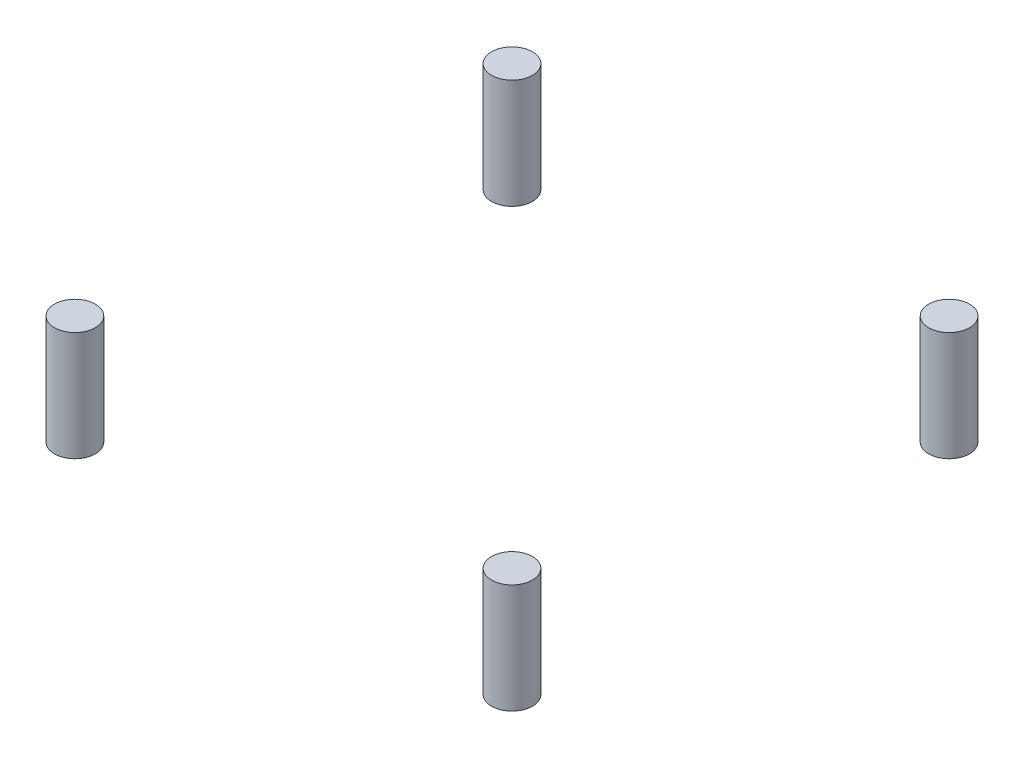
from build123d import *

# Parameters (mm, degrees)
SKETCH1_R             = 3.104394748
BOSS_EXTRUDE1_DEPTH   = 16.6
BOSS_EXTRUDE1_2_DEPTH = 16.6
BOSS_EXTRUDE1_3_DEPTH = 16.6
BOSS_EXTRUDE1_4_DEPTH = 16.6


with BuildPart() as part:
    # Sketch1 → Boss-Extrude1 (new body)
    with BuildSketch(Plane(origin=(0, 0, 0), x_dir=(1, 0, 0), z_dir=(0, 1, 0))):
        with Locations((-33.200350973, 33.200350973)):
            Circle(SKETCH1_R)
    extrude(amount=BOSS_EXTRUDE1_DEPTH)


with BuildPart() as body_2:
    # Sketch1 → Boss-Extrude1 2 (new body)
    with BuildSketch(Plane(origin=(0, 0, 0), x_dir=(1, 0, 0), z_dir=(0, 1, 0))):
        with Locations((33.200350973, 33.200350973)):
            Circle(SKETCH1_R)
    extrude(amount=BOSS_EXTRUDE1_2_DEPTH)


with BuildPart() as body_3:
    # Sketch1 → Boss-Extrude1 3 (new body)
    with BuildSketch(Plane(origin=(0, 0, 0), x_dir=(1, 0, 0), z_dir=(0, 1, 0))):
        with Locations((33.200350973, -33.200350973)):
            Circle(SKETCH1_R)
    extrude(amount=BOSS_EXTRUDE1_3_DEPTH)


with BuildPart() as body_4:
    # Sketch1 → Boss-Extrude1 4 (new body)
    with BuildSketch(Plane(origin=(0, 0, 0), x_dir=(1, 0, 0), z_dir=(0, 1, 0))):
        with Locations((-33.200350973, -33.200350973)):
            Circle(SKETCH1_R)
    extrude(amount=BOSS_EXTRUDE1_4_DEPTH)


solid = Compound([part.part, body_2.part, body_3.part, body_4.part])
